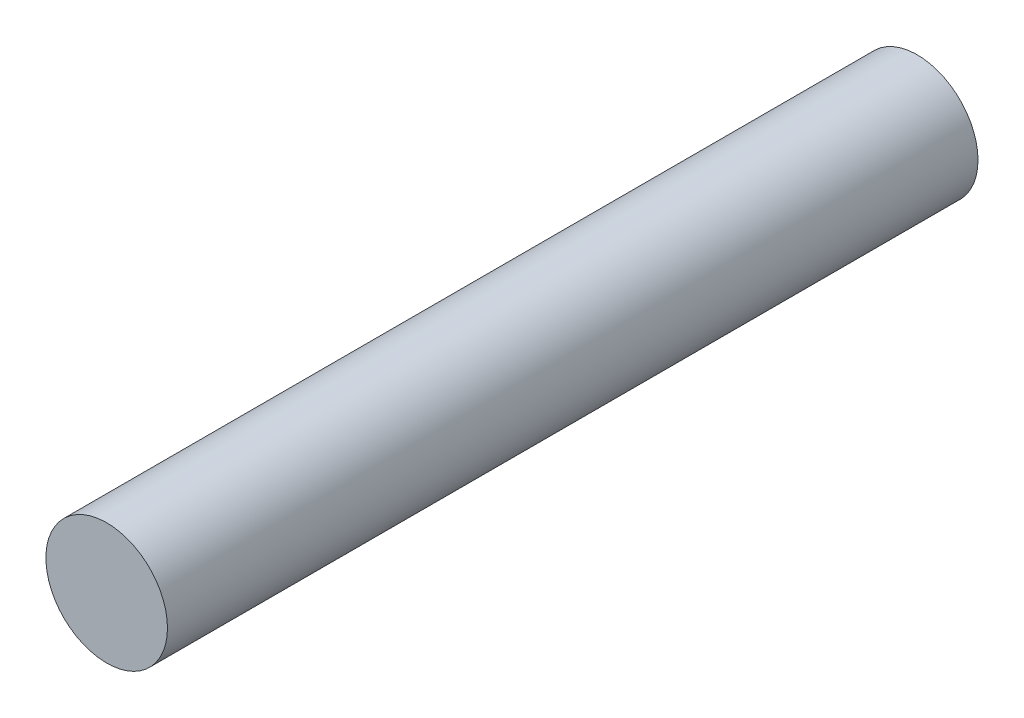
from build123d import *

# Parameters (mm, degrees)
ESQUISSE1_R        = 3
BOSS_EXTRU_1_DEPTH = 20


with BuildPart() as part:
    # Esquisse1 → Boss.-Extru.1 (new body, symmetric)
    with BuildSketch(Plane.XY):
        Circle(ESQUISSE1_R)
    extrude(amount=BOSS_EXTRU_1_DEPTH, both=True)


solid = part.part
